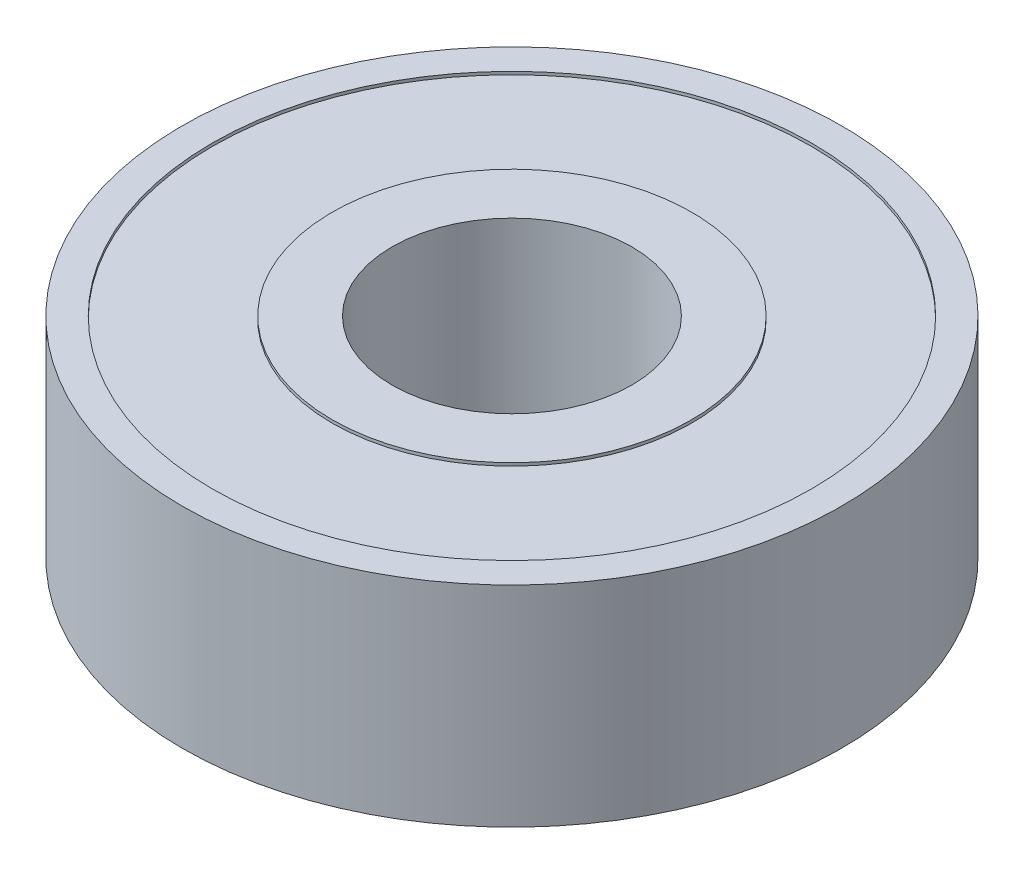
from build123d import *

# Parameters (mm, degrees)
SKETCH1_R           = 11
SKETCH1_R_2         = 4
BOSS_EXTRUDE1_DEPTH = 3.5
SKETCH2_R           = 10
SKETCH2_R_2         = 6
CUT_EXTRUDE1_DEPTH  = 0.1


with BuildPart() as part:
    # Sketch1 → Boss-Extrude1 (new body, symmetric)
    with BuildSketch(Plane(origin=(0, 0, 0), x_dir=(1, 0, 0), z_dir=(0, 1, 0))):
        Circle(SKETCH1_R)
        Circle(SKETCH1_R_2, mode=Mode.SUBTRACT)
    extrude(amount=BOSS_EXTRUDE1_DEPTH, both=True)

    # Sketch2 → Cut-Extrude1 (cut)
    with BuildSketch(Plane(origin=(0, 3.5, 0), x_dir=(1, 0, 0), z_dir=(0, 1, 0))):
        Circle(SKETCH2_R)
        Circle(SKETCH2_R_2, mode=Mode.SUBTRACT)
    cut_extrude1 = extrude(amount=-CUT_EXTRUDE1_DEPTH, mode=Mode.SUBTRACT)

    # Mirror1: Cut-Extrude1 across plane
    add(cut_extrude1.mirror(Plane.ZX), mode=Mode.SUBTRACT)


solid = part.part
